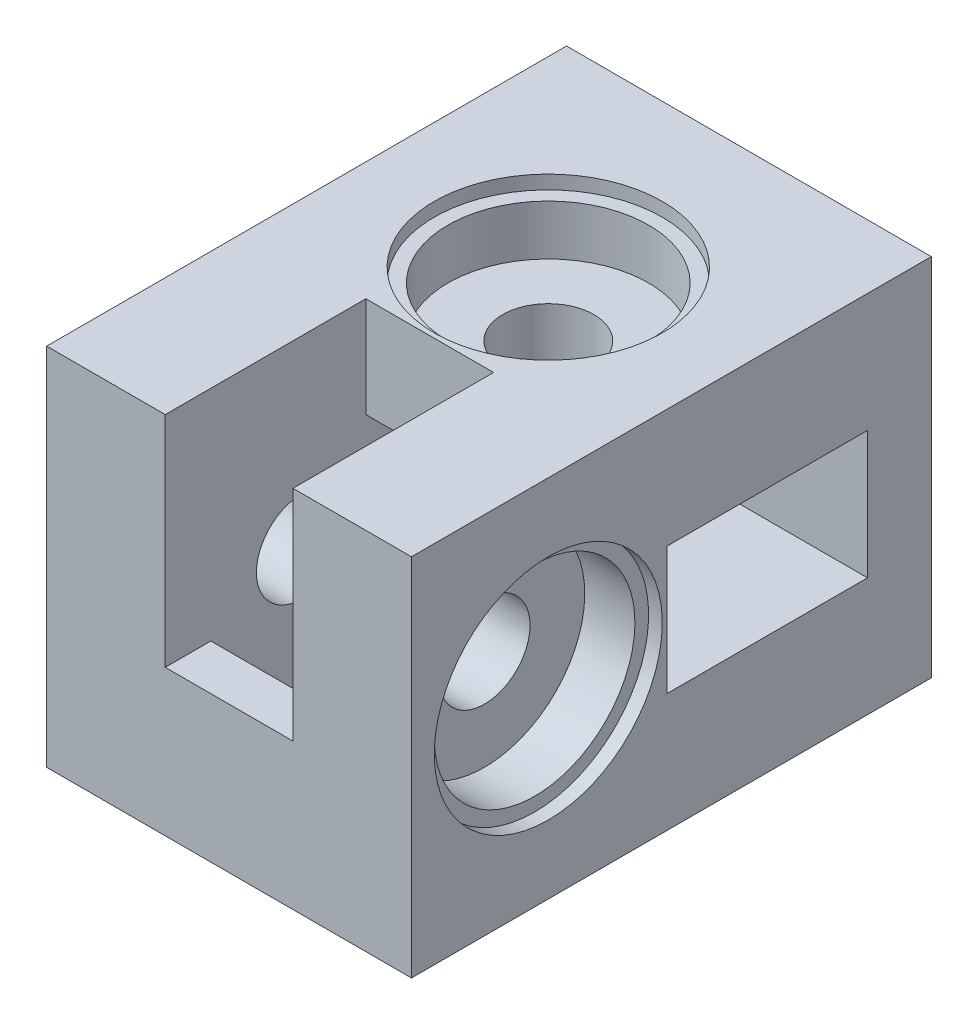
from build123d import *

# Parameters (mm, degrees)
ESQUISSE1_W              = 40
ESQUISSE1_H              = 40
BOSS_EXTRU_1_DEPTH       = 50
ESQUISSE2_R              = 5
ENL_V_MAT_EXTRU_1_DEPTH  = 41
ESQUISSE3_R              = 5
ENL_V_MAT_EXTRU_2_DEPTH  = 41
ESQUISSE4_W              = 20
ESQUISSE4_H              = 14
ENL_V_MAT_EXTRU_3_DEPTH  = 29
ESQUISSE5_W              = 14
ESQUISSE5_H              = 20
ENL_V_MAT_EXTRU_4_DEPTH  = 29
ESQUISSE6_W              = 22
ESQUISSE6_H              = 14
ENL_V_MAT_EXTRU_5_DEPTH  = 24
ESQUISSE7_W              = 14
ESQUISSE7_H              = 22
ENL_V_MAT_EXTRU_6_DEPTH  = 24
ESQUISSE8_R              = 11
ENL_V_MAT_EXTRU_7_DEPTH  = 7
ESQUISSE9_R              = 12.5
ENL_V_MAT_EXTRU_8_DEPTH  = 1.5
ESQUISSE10_R             = 11
ENL_V_MAT_EXTRU_9_DEPTH  = 7
ESQUISSE11_R             = 12.5
ENL_V_MAT_EXTRU_10_DEPTH = 1.5
ESQUISSE12_W             = 40
ESQUISSE12_H             = 40
BOSS_EXTRU_2_DEPTH       = 7
ESQUISSE13_R             = 2.25
ENL_V_MAT_EXTRU_11_DEPTH = 15
ESQUISSE14_W             = 3
ESQUISSE14_H             = 7
ENL_V_MAT_EXTRU_12_DEPTH = 12
ESQUISSE15_W             = 7
ESQUISSE15_H             = 3
ENL_V_MAT_EXTRU_13_DEPTH = 12


with BuildPart() as part:
    # Esquisse1 → Boss.-Extru.1 (new body)
    with BuildSketch(Plane.XY):
        with Locations((-20, 20)):
            Rectangle(ESQUISSE1_W, ESQUISSE1_H)
    extrude(amount=BOSS_EXTRU_1_DEPTH)

    # Esquisse2 → Enlèv. mat.-Extru.1 (cut, through all)
    with BuildSketch(Plane(origin=(0, 40, 0), x_dir=(1, 0, 0), z_dir=(0, 1, 0))):
        with Locations(Location((-20, -15, 0), (0, 0, 270))):  # turned: the seam where the file's is
            Circle(ESQUISSE2_R)
    extrude(amount=-ENL_V_MAT_EXTRU_1_DEPTH, mode=Mode.SUBTRACT)

    # Esquisse3 → Enlèv. mat.-Extru.2 (cut, through all)
    with BuildSketch(Plane.ZY.offset(40)):
        with Locations((35, 20)):
            Circle(ESQUISSE3_R)
    extrude(amount=-ENL_V_MAT_EXTRU_2_DEPTH, mode=Mode.SUBTRACT)

    # Esquisse4 → Enlèv. mat.-Extru.3 (cut)
    with BuildSketch(Plane.ZY.offset(40)):
        with Locations((15, 20)):
            Rectangle(ESQUISSE4_W, ESQUISSE4_H)
    extrude(amount=-ENL_V_MAT_EXTRU_3_DEPTH, mode=Mode.SUBTRACT)

    # Esquisse5 → Enlèv. mat.-Extru.4 (cut)
    with BuildSketch(Plane.XZ):
        with Locations((-20, 35)):
            Rectangle(ESQUISSE5_W, ESQUISSE5_H)
    extrude(amount=-ENL_V_MAT_EXTRU_4_DEPTH, mode=Mode.SUBTRACT)

    # Esquisse6 → Enlèv. mat.-Extru.5 (cut)
    with BuildSketch(Plane(origin=(0, 0, 0), x_dir=(0, 0, -1), z_dir=(1, 0, 0))):
        with Locations((-11, 20)):
            Rectangle(ESQUISSE6_W, ESQUISSE6_H)
    extrude(amount=-ENL_V_MAT_EXTRU_5_DEPTH, mode=Mode.SUBTRACT)

    # Esquisse7 → Enlèv. mat.-Extru.6 (cut)
    with BuildSketch(Plane(origin=(0, 40, 0), x_dir=(1, 0, 0), z_dir=(0, 1, 0))):
        with Locations((-20, -39)):
            Rectangle(ESQUISSE7_W, ESQUISSE7_H)
    extrude(amount=-ENL_V_MAT_EXTRU_6_DEPTH, mode=Mode.SUBTRACT)

    # Esquisse8 → Enlèv. mat.-Extru.7 (cut)
    with BuildSketch(Plane(origin=(0, 0, 0), x_dir=(0, 0, -1), z_dir=(1, 0, 0))):
        with Locations(Location((-35, 20, 0), (0, 0, 90))):  # turned: the seam where the file's is
            Circle(ESQUISSE8_R)
    extrude(amount=-ENL_V_MAT_EXTRU_7_DEPTH, mode=Mode.SUBTRACT)

    # Esquisse9 → Enlèv. mat.-Extru.8 (cut)
    with BuildSketch(Plane(origin=(0, 0, 0), x_dir=(0, 0, -1), z_dir=(1, 0, 0))):
        with Locations(Location((-35, 20, 0), (0, 0, 90))):  # turned: the seam where the file's is
            Circle(ESQUISSE9_R)
    extrude(amount=-ENL_V_MAT_EXTRU_8_DEPTH, mode=Mode.SUBTRACT)

    # Esquisse10 → Enlèv. mat.-Extru.9 (cut)
    with BuildSketch(Plane(origin=(0, 40, 0), x_dir=(1, 0, 0), z_dir=(0, 1, 0))):
        with Locations(Location((-20, -15, 0), (0, 0, 270))):  # turned: the seam where the file's is
            Circle(ESQUISSE10_R)
    extrude(amount=-ENL_V_MAT_EXTRU_9_DEPTH, mode=Mode.SUBTRACT)

    # Esquisse11 → Enlèv. mat.-Extru.10 (cut)
    with BuildSketch(Plane(origin=(0, 40, 0), x_dir=(1, 0, 0), z_dir=(0, 1, 0))):
        with Locations(Location((-20, -15, 0), (0, 0, 270))):  # turned: the seam where the file's is
            Circle(ESQUISSE11_R)
    extrude(amount=-ENL_V_MAT_EXTRU_10_DEPTH, mode=Mode.SUBTRACT)

    # Esquisse12 → Boss.-Extru.2 (add)
    with BuildSketch(Plane(origin=(0, 0, 0), x_dir=(-1, 0, 0), z_dir=(0, 0, -1))):
        with Locations((20, 20)):
            Rectangle(ESQUISSE12_W, ESQUISSE12_H)
    extrude(amount=BOSS_EXTRU_2_DEPTH)

    # Esquisse13 → Enlèv. mat.-Extru.11 (cut)
    with BuildSketch(Plane(origin=(0, 0, -7), x_dir=(-1, 0, 0), z_dir=(0, 0, -1))):
        with Locations((10, 7.5)):
            Circle(ESQUISSE13_R)
        with Locations((32.5, 30)):
            Circle(ESQUISSE13_R)
    extrude(amount=-ENL_V_MAT_EXTRU_11_DEPTH, mode=Mode.SUBTRACT)

    # Esquisse14 → Enlèv. mat.-Extru.12 (cut)
    with BuildSketch(Plane.ZY.offset(40)):
        with Locations((-1.5, 30)):
            Rectangle(ESQUISSE14_W, ESQUISSE14_H)
    extrude(amount=-ENL_V_MAT_EXTRU_12_DEPTH, mode=Mode.SUBTRACT)

    # Esquisse15 → Enlèv. mat.-Extru.13 (cut)
    with BuildSketch(Plane.XZ):
        with Locations((-10, -1.5)):
            Rectangle(ESQUISSE15_W, ESQUISSE15_H)
    extrude(amount=-ENL_V_MAT_EXTRU_13_DEPTH, mode=Mode.SUBTRACT)


solid = part.part
